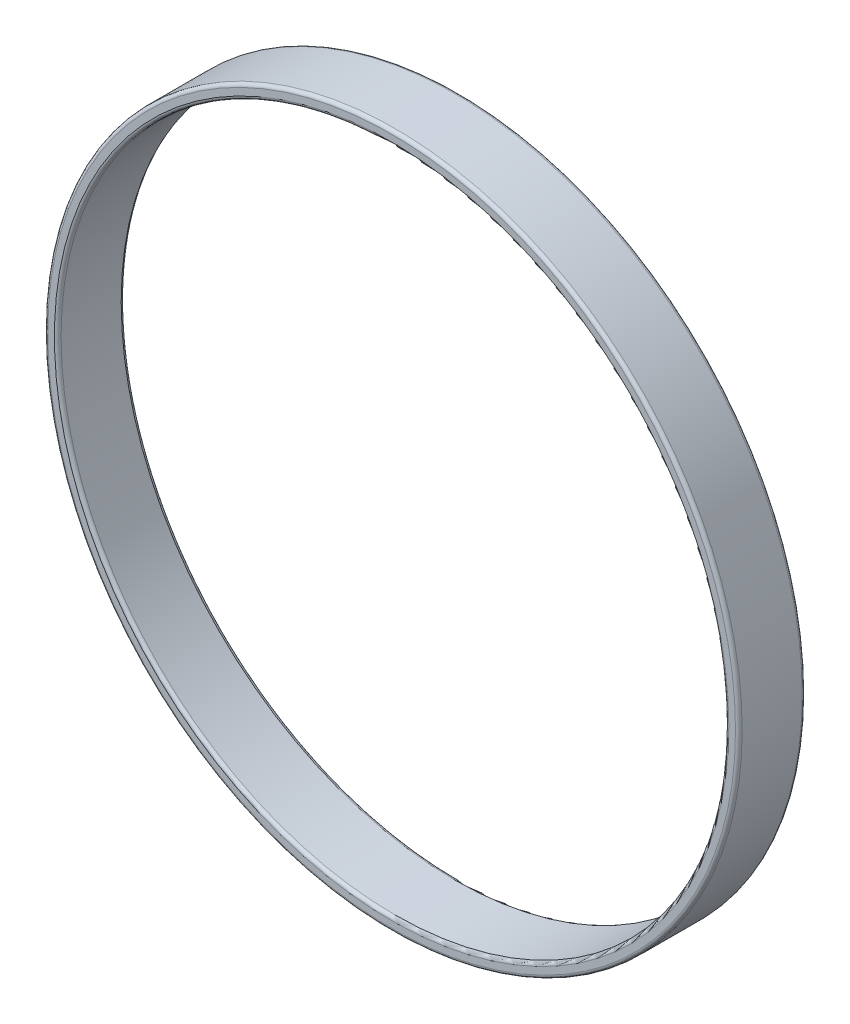
from build123d import *

# Parameters (mm, degrees)
SKETCH1_R           = 52
SKETCH1_R_2         = 50
BOSS_EXTRUDE1_DEPTH = 10
FILLET1_R           = 0.5


with BuildPart() as part:
    # Sketch1 → Boss-Extrude1 (new body)
    with BuildSketch(Plane.XY):
        Circle(SKETCH1_R)
        Circle(SKETCH1_R_2, mode=Mode.SUBTRACT)
    extrude(amount=BOSS_EXTRUDE1_DEPTH)

    # Fillet1
    fillet1_edges = [part.edges().sort_by_distance(p)[0] for p in [
        (-52, 0, 0),
        (-52, 0, 10),
        (-50, 0, 0),
        (-50, 0, 10),
    ]]
    fillet(fillet1_edges, radius=FILLET1_R)


solid = part.part
